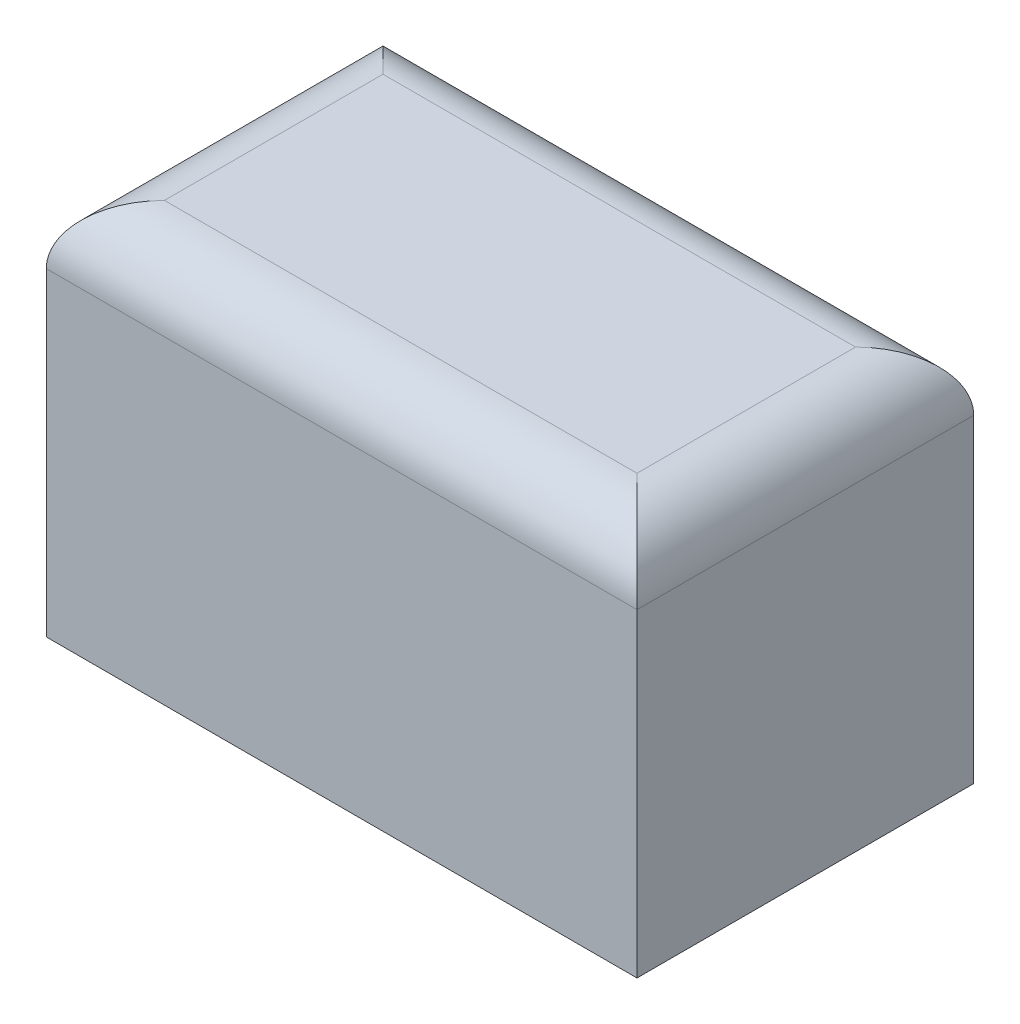
from build123d import *

# Parameters (mm, degrees)
SKETCH1_W           = 10
SKETCH1_H           = 5.7
BOSS_EXTRUDE1_DEPTH = 6.4
FILLET1_R           = 1


with BuildPart() as part:
    # Sketch1 → Boss-Extrude1 (new body)
    with BuildSketch(Plane(origin=(0, 0, 0), x_dir=(1, 0, 0), z_dir=(0, 1, 0))):
        Rectangle(SKETCH1_W, SKETCH1_H)
    extrude(amount=BOSS_EXTRUDE1_DEPTH)

    # Fillet1
    fillet1_edges = [part.edges().sort_by_distance(p)[0] for p in [
        (-5, 6.4, 0),
        (0, 6.4, 2.85),
        (5, 6.4, 0),
        (0, 6.4, -2.85),
    ]]
    fillet(fillet1_edges, radius=FILLET1_R)


solid = part.part
